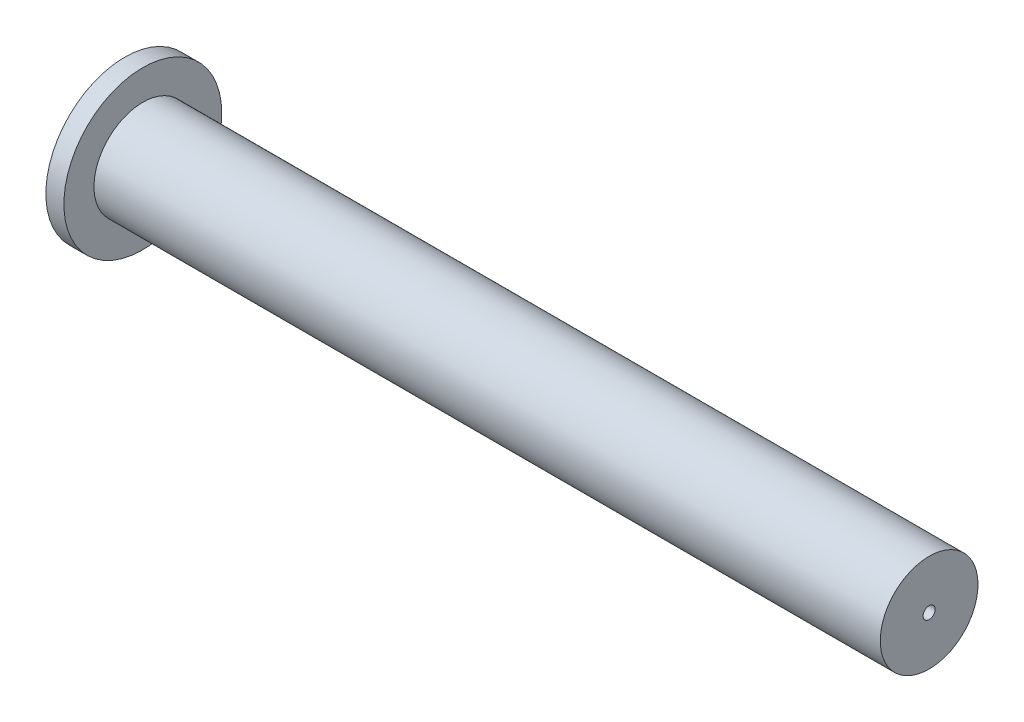
from build123d import *


with BuildPart() as part:
    # Sketch1 → Revolve1 (revolve)
    with BuildSketch(Plane.XY):
        Polygon((11, 0.4), (11, 3.25), (-41.3, 3.25), (-41.3, 5.25), (-42.5, 5.25), (-42.5, 2.25), (10, 2.25), (10, 0.4), align=None)
    revolve(axis=Axis((13.5, 0, 0), (-1, 0, 0)))


solid = part.part
